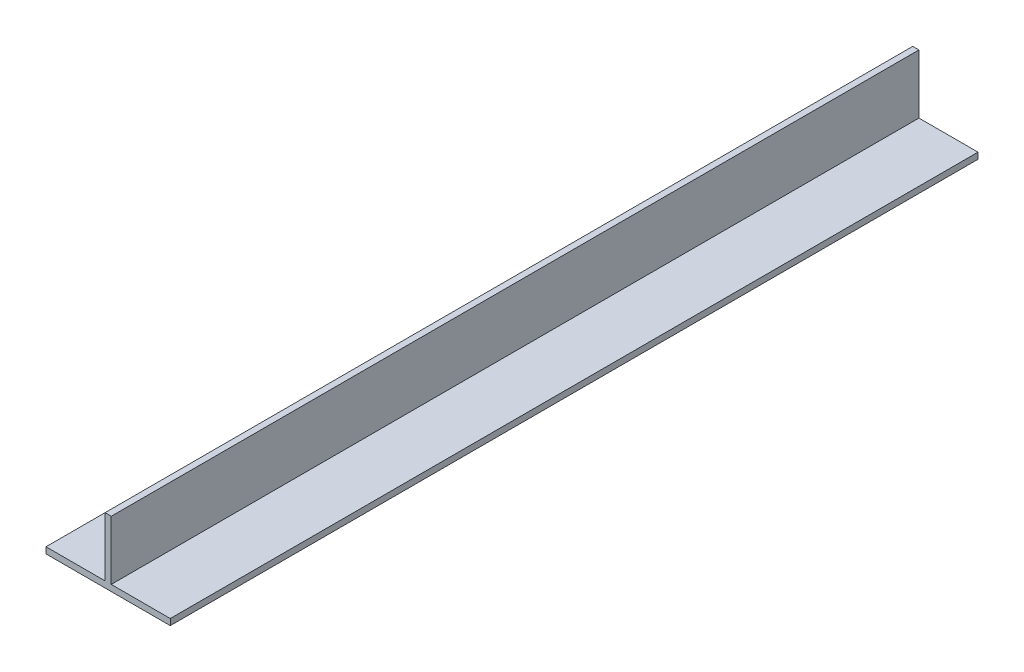
from build123d import *

# Parameters (mm, degrees)
SALIENTE_EXTRUIR1_DEPTH = 65


with BuildPart() as part:
    # Croquis1 → Saliente-Extruir1 (new body, symmetric)
    with BuildSketch(Plane.XY):
        Polygon((-10, 0), (-0.5, 0), (-0.5, 9.5), (0.5, 9.5), (0.5, 0), (10, 0), (10, -1), (-10, -1), align=None)
    extrude(amount=SALIENTE_EXTRUIR1_DEPTH, both=True)


solid = part.part
